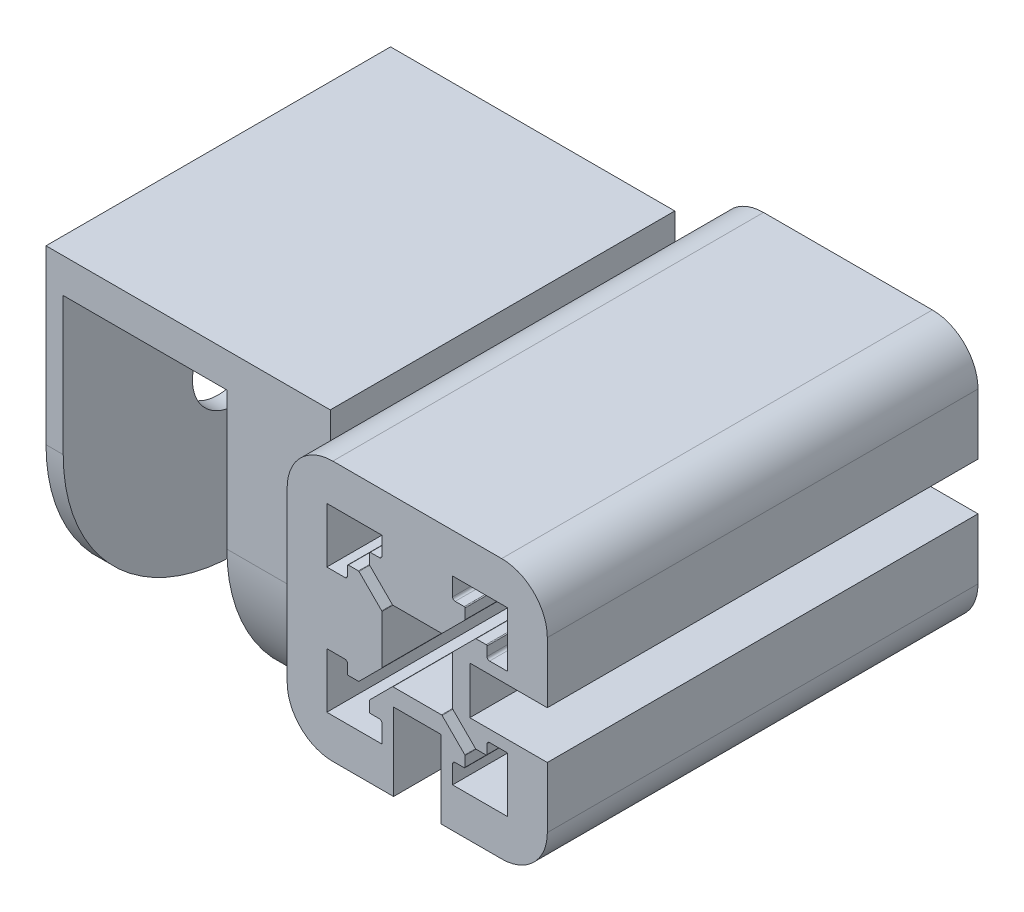
from build123d import *

# Parameters (mm, degrees)
Y_KSEKLIK_EKSTR_ZYON3_DEPTH       = 25
IZIM8_W                           = 20
IZIM8_H                           = 5.3
IZIM8_H_2                         = 14.7
IZIM8_H_3                         = 15.1
IZIM8_H_4                         = 4.9
Y_KSEKLIK_EKSTR_ZYON4_DEPTH       = 33
IZIM9_W                           = 19
IZIM9_H                           = 36
KES_EKSTR_ZYON1_DEPTH             = 36
IZIM11_R                          = 5
KES_EKSTR_ZYON3_DEPTH             = 10
IZIM12_W                          = 19
IZIM12_H                          = 36
KES_EKSTR_ZYON4_DEPTH             = 93
KES_EKSTR_ZYON5_REACH             = 76.836
KES_EKSTR_ZYON5_DIRECTION_2_DEPTH = 2


with BuildPart() as part:
    # izim6 → Y_kseklik-Ekstr_zyon3 (new, symmetric)
    with BuildSketch(Plane.XY):
        with BuildLine():
            Line((-119.371512251, 18.973770729), (-115.371512251, 18.973770729))
            Line((-115.371512251, 18.973770729), (-110.371512251, 18.973770729))
            Line((-110.371512251, 18.973770729), (-110.371512251, 20.773770729))
            Line((-110.371512251, 20.773770729), (-110.371512251, 26.023770729))
            ThreePointArc((-110.371512251, 26.023770729), (-111.92384631, 29.771436669), (-115.671512251, 31.323770729))
            Line((-115.671512251, 31.323770729), (-120.921512251, 31.323770729))
            Line((-120.921512251, 31.323770729), (-122.721512251, 31.323770729))
            Line((-122.721512251, 31.323770729), (-128.221512251, 31.323770729))
            Line((-128.221512251, 31.323770729), (-130.021512251, 31.323770729))
            Line((-130.021512251, 31.323770729), (-135.271512251, 31.323770729))
            ThreePointArc((-135.271512251, 31.323770729), (-139.019178191, 29.771436669), (-140.571512251, 26.023770729))
            Line((-140.571512251, 26.023770729), (-140.571512251, 20.773770729))
            Line((-140.571512251, 20.773770729), (-140.571512251, 16.223770729))
            Line((-140.571512251, 16.223770729), (-140.571512251, 11.673770729))
            Line((-140.571512251, 11.673770729), (-140.571512251, 6.423770729))
            ThreePointArc((-140.571512251, 6.423770729), (-139.019178191, 2.676104789), (-135.271512251, 1.123770729))
            Line((-135.271512251, 1.123770729), (-130.021512251, 1.123770729))
            Line((-130.021512251, 1.123770729), (-128.221512251, 1.123770729))
            Line((-128.221512251, 1.123770729), (-128.221512251, 6.123770729))
            Line((-128.221512251, 6.123770729), (-128.221512251, 10.123770729))
            Line((-128.221512251, 10.123770729), (-122.721512251, 10.123770729))
            Line((-122.721512251, 10.123770729), (-122.721512251, 6.123770729))
            Line((-122.721512251, 6.123770729), (-122.721512251, 1.123770729))
            Line((-122.721512251, 1.123770729), (-120.921512251, 1.123770729))
            Line((-120.921512251, 1.123770729), (-115.671512251, 1.123770729))
            ThreePointArc((-115.671512251, 1.123770729), (-111.92384631, 2.676104789), (-110.371512251, 6.423770729))
            Line((-110.371512251, 6.423770729), (-110.371512251, 11.673770729))
            Line((-110.371512251, 11.673770729), (-110.371512251, 13.473770729))
            Line((-110.371512251, 13.473770729), (-115.371512251, 13.473770729))
            Line((-115.371512251, 13.473770729), (-119.371512251, 13.473770729))
            Line((-119.371512251, 13.473770729), (-119.371512251, 18.973770729))
        make_face()
        with BuildLine():
            Line((-133.871512251, 20.323770729), (-135.071512251, 20.323770729))
            Line((-135.071512251, 20.323770729), (-135.871512251, 20.323770729))
            Line((-135.871512251, 20.323770729), (-135.971512251, 20.323770729))
            Line((-135.971512251, 20.323770729), (-135.971512251, 26.723770729))
            Line((-135.971512251, 26.723770729), (-129.571512251, 26.723770729))
            Line((-129.571512251, 26.723770729), (-129.571512251, 26.623770729))
            Line((-129.571512251, 26.623770729), (-129.571512251, 25.823770729))
            Line((-129.571512251, 25.823770729), (-129.571512251, 24.623770729))
            ThreePointArc((-129.571512251, 24.623770729), (-129.659380216, 24.411638694), (-129.871512251, 24.323770729))
            Line((-129.871512251, 24.323770729), (-130.921512251, 24.323770729))
            ThreePointArc((-130.921512251, 24.323770729), (-130.992222929, 24.294481407), (-131.021512251, 24.223770729))
            Line((-131.021512251, 24.223770729), (-131.021512251, 23.056613441))
            ThreePointArc((-131.021512251, 23.056613441), (-131.013900204, 23.018345098), (-130.992222929, 22.985902763))
            Line((-130.992222929, 22.985902763), (-128.359380216, 20.353060051))
            ThreePointArc((-128.359380216, 20.353060051), (-128.326937882, 20.331382776), (-128.288669538, 20.323770729))
            Line((-128.288669538, 20.323770729), (-122.654354963, 20.323770729))
            ThreePointArc((-122.654354963, 20.323770729), (-122.61608662, 20.331382776), (-122.583644285, 20.353060051))
            Line((-122.583644285, 20.353060051), (-119.950801573, 22.985902763))
            ThreePointArc((-119.950801573, 22.985902763), (-119.929124298, 23.018345098), (-119.921512251, 23.056613441))
            Line((-119.921512251, 23.056613441), (-119.921512251, 24.223770729))
            ThreePointArc((-119.921512251, 24.223770729), (-119.950801573, 24.294481407), (-120.021512251, 24.323770729))
            Line((-120.021512251, 24.323770729), (-121.071512251, 24.323770729))
            ThreePointArc((-121.071512251, 24.323770729), (-121.283644285, 24.411638694), (-121.371512251, 24.623770729))
            Line((-121.371512251, 24.623770729), (-121.371512251, 25.823770729))
            Line((-121.371512251, 25.823770729), (-121.371512251, 26.323770729))
            Line((-121.371512251, 26.323770729), (-121.371512251, 26.723770729))
            Line((-121.371512251, 26.723770729), (-114.971512251, 26.723770729))
            Line((-114.971512251, 26.723770729), (-114.971512251, 20.323770729))
            Line((-114.971512251, 20.323770729), (-115.371512251, 20.323770729))
            Line((-115.371512251, 20.323770729), (-115.871512251, 20.323770729))
            Line((-115.871512251, 20.323770729), (-117.071512251, 20.323770729))
            ThreePointArc((-117.071512251, 20.323770729), (-117.283644285, 20.411638694), (-117.371512251, 20.623770729))
            Line((-117.371512251, 20.623770729), (-117.371512251, 21.673770729))
            ThreePointArc((-117.371512251, 21.673770729), (-117.400801573, 21.744481407), (-117.471512251, 21.773770729))
            Line((-117.471512251, 21.773770729), (-118.638669538, 21.773770729))
            ThreePointArc((-118.638669538, 21.773770729), (-118.676937882, 21.766158682), (-118.709380216, 21.744481407))
            Line((-118.709380216, 21.744481407), (-121.342222929, 19.111638694))
            ThreePointArc((-121.342222929, 19.111638694), (-121.363900204, 19.07919636), (-121.371512251, 19.040928016))
            Line((-121.371512251, 19.040928016), (-121.371512251, 13.406613441))
            ThreePointArc((-121.371512251, 13.406613441), (-121.363900204, 13.368345098), (-121.342222929, 13.335902763))
            Line((-121.342222929, 13.335902763), (-118.709380216, 10.703060051))
            ThreePointArc((-118.709380216, 10.703060051), (-118.676937882, 10.681382776), (-118.638669538, 10.673770729))
            Line((-118.638669538, 10.673770729), (-117.471512251, 10.673770729))
            ThreePointArc((-117.471512251, 10.673770729), (-117.400801573, 10.703060051), (-117.371512251, 10.773770729))
            Line((-117.371512251, 10.773770729), (-117.371512251, 11.823770729))
            ThreePointArc((-117.371512251, 11.823770729), (-117.283644285, 12.035902763), (-117.071512251, 12.123770729))
            Line((-117.071512251, 12.123770729), (-115.871512251, 12.123770729))
            Line((-115.871512251, 12.123770729), (-115.371512251, 12.123770729))
            Line((-115.371512251, 12.123770729), (-114.971512251, 12.123770729))
            Line((-114.971512251, 12.123770729), (-114.971512251, 5.723770729))
            Line((-114.971512251, 5.723770729), (-121.371512251, 5.723770729))
            Line((-121.371512251, 5.723770729), (-121.371512251, 6.123770729))
            Line((-121.371512251, 6.123770729), (-121.371512251, 6.623770729))
            Line((-121.371512251, 6.623770729), (-121.371512251, 7.823770729))
            ThreePointArc((-121.371512251, 7.823770729), (-121.283644285, 8.035902763), (-121.071512251, 8.123770729))
            Line((-121.071512251, 8.123770729), (-120.021512251, 8.123770729))
            ThreePointArc((-120.021512251, 8.123770729), (-119.950801573, 8.153060051), (-119.921512251, 8.223770729))
            Line((-119.921512251, 8.223770729), (-119.921512251, 9.390928016))
            ThreePointArc((-119.921512251, 9.390928016), (-119.929124298, 9.42919636), (-119.950801573, 9.461638694))
            Line((-119.950801573, 9.461638694), (-122.583644285, 12.094481407))
            ThreePointArc((-122.583644285, 12.094481407), (-122.61608662, 12.116158682), (-122.654354963, 12.123770729))
            Line((-122.654354963, 12.123770729), (-128.288669538, 12.123770729))
            ThreePointArc((-128.288669538, 12.123770729), (-128.326937882, 12.116158682), (-128.359380216, 12.094481407))
            Line((-128.359380216, 12.094481407), (-130.992222929, 9.461638694))
            ThreePointArc((-130.992222929, 9.461638694), (-131.013900204, 9.42919636), (-131.021512251, 9.390928016))
            Line((-131.021512251, 9.390928016), (-131.021512251, 8.223770729))
            ThreePointArc((-131.021512251, 8.223770729), (-130.992222929, 8.153060051), (-130.921512251, 8.123770729))
            Line((-130.921512251, 8.123770729), (-129.871512251, 8.123770729))
            ThreePointArc((-129.871512251, 8.123770729), (-129.659380216, 8.035902763), (-129.571512251, 7.823770729))
            Line((-129.571512251, 7.823770729), (-129.571512251, 6.623770729))
            Line((-129.571512251, 6.623770729), (-129.571512251, 6.123770729))
            Line((-129.571512251, 6.123770729), (-129.571512251, 5.723770729))
            Line((-129.571512251, 5.723770729), (-135.971512251, 5.723770729))
            Line((-135.971512251, 5.723770729), (-135.971512251, 12.123770729))
            Line((-135.971512251, 12.123770729), (-135.571512251, 12.123770729))
            Line((-135.571512251, 12.123770729), (-135.071512251, 12.123770729))
            Line((-135.071512251, 12.123770729), (-133.871512251, 12.123770729))
            ThreePointArc((-133.871512251, 12.123770729), (-133.659380216, 12.035902763), (-133.571512251, 11.823770729))
            Line((-133.571512251, 11.823770729), (-133.571512251, 10.773770729))
            ThreePointArc((-133.571512251, 10.773770729), (-133.542222929, 10.703060051), (-133.471512251, 10.673770729))
            Line((-133.471512251, 10.673770729), (-132.304354963, 10.673770729))
            ThreePointArc((-132.304354963, 10.673770729), (-132.26608662, 10.681382776), (-132.233644285, 10.703060051))
            Line((-132.233644285, 10.703060051), (-129.600801573, 13.335902763))
            ThreePointArc((-129.600801573, 13.335902763), (-129.579124298, 13.368345098), (-129.571512251, 13.406613441))
            Line((-129.571512251, 13.406613441), (-129.571512251, 19.040928016))
            ThreePointArc((-129.571512251, 19.040928016), (-129.579124298, 19.07919636), (-129.600801573, 19.111638694))
            Line((-129.600801573, 19.111638694), (-132.233644285, 21.744481407))
            ThreePointArc((-132.233644285, 21.744481407), (-132.26608662, 21.766158682), (-132.304354963, 21.773770729))
            Line((-132.304354963, 21.773770729), (-133.471512251, 21.773770729))
            ThreePointArc((-133.471512251, 21.773770729), (-133.542222929, 21.744481407), (-133.571512251, 21.673770729))
            Line((-133.571512251, 21.673770729), (-133.571512251, 20.623770729))
            ThreePointArc((-133.571512251, 20.623770729), (-133.659380216, 20.411638694), (-133.871512251, 20.323770729))
        make_face(mode=Mode.SUBTRACT)
    extrude(amount=Y_KSEKLIK_EKSTR_ZYON3_DEPTH, both=True)

    # izim8 → Y_kseklik-Ekstr_zyon4 (add)
    with BuildSketch(Plane.ZY.offset(140.571512251)):
        with Locations((-10, 28.673770729)):
            Rectangle(IZIM8_W, IZIM8_H)
        with Locations((10, 28.673770729)):
            Rectangle(IZIM8_W, IZIM8_H)
        with Locations((10, 18.673770729)):
            Rectangle(IZIM8_W, IZIM8_H_2)
        with Locations((-10, 18.673770729)):
            Rectangle(IZIM8_W, IZIM8_H_2)
        with Locations((-10, -1.126229271)):
            Rectangle(IZIM8_W, IZIM8_H_3)
        with Locations((-10, 8.873770729)):
            Rectangle(IZIM8_W, IZIM8_H_4)
        with Locations((10, 8.873770729)):
            Rectangle(IZIM8_W, IZIM8_H_4)
        with Locations((10, -1.126229271)):
            Rectangle(IZIM8_W, IZIM8_H_3)
    extrude(amount=Y_KSEKLIK_EKSTR_ZYON4_DEPTH)

    # izim9 → Kes-Ekstr_zyon1 (cut)
    with BuildSketch(Plane.XZ.offset(8.676229271)):
        with Locations((-162.071512251, 0)):
            Rectangle(IZIM9_W, IZIM9_H)
    extrude(amount=-KES_EKSTR_ZYON1_DEPTH, mode=Mode.SUBTRACT)

    # izim11 → Kes-Ekstr_zyon3 (cut)
    with BuildSketch(Plane.ZY.offset(173.571512251)):
        with Locations(Location((0, 11.323770729, 0), (0, 0, 270))):
            Circle(IZIM11_R)
    extrude(amount=-KES_EKSTR_ZYON3_DEPTH, mode=Mode.SUBTRACT)

    # izim12 → Kes-Ekstr_zyon4 (cut)
    with BuildSketch(Plane(origin=(0, 0, -20), x_dir=(-1, 0, 0), z_dir=(0, 0, -1))):
        with Locations((162.071512251, 9.323770729)):
            Rectangle(IZIM12_W, IZIM12_H)
    extrude(amount=-KES_EKSTR_ZYON4_DEPTH, mode=Mode.SUBTRACT)

    # Kes-Ekstr_zyon5: up to this face of the body (flat: up to its plane)
    kes_ekstr_zyon5_end = Plane(part.part.faces().sort_by_distance((-140.571512251, -1.126229271, 0))[0])
    # izim13 → Kes-Ekstr_zyon5 (cut, up to the picked face)
    with BuildSketch(Plane.ZY.offset(173.571512251), mode=Mode.PRIVATE) as kes_ekstr_zyon5_sk1:
        with BuildLine():
            Line((-20, 11.323770729), (-20, -8.676229271))
            Line((-20, -8.676229271), (3.8e-08, -8.676229271))
            ThreePointArc((3.8e-08, -8.676229271), (-14.14213561, -2.818364908), (-20, 11.323770729))
        make_face()
    kes_ekstr_zyon5_tool1 = split(extrude(kes_ekstr_zyon5_sk1.sketch, amount=-KES_EKSTR_ZYON5_REACH, mode=Mode.PRIVATE), bisect_by=kes_ekstr_zyon5_end, keep=Keep.BOTH, mode=Mode.PRIVATE)
    # izim13 → Kes-Ekstr_zyon5 (cut, up to the picked face)
    with BuildSketch(Plane.ZY.offset(173.571512251), mode=Mode.PRIVATE) as kes_ekstr_zyon5_sk2:
        with BuildLine():
            ThreePointArc((20, 11.323770729), (14.142135637, -2.818364882), (3.8e-08, -8.676229271))
            Line((3.8e-08, -8.676229271), (20, -8.676229271))
            Line((20, -8.676229271), (20, 11.323770729))
        make_face()
    kes_ekstr_zyon5_tool2 = split(extrude(kes_ekstr_zyon5_sk2.sketch, amount=-KES_EKSTR_ZYON5_REACH, mode=Mode.PRIVATE), bisect_by=kes_ekstr_zyon5_end, keep=Keep.BOTH, mode=Mode.PRIVATE)
    add(kes_ekstr_zyon5_tool1.solids().sort_by(Axis((-173.571512, -4.20887, -15.532641), (1, 0, 0)))[0], mode=Mode.SUBTRACT)
    add(kes_ekstr_zyon5_tool2.solids().sort_by(Axis((-173.571512, -4.20887, 15.532641), (1, 0, 0)))[0], mode=Mode.SUBTRACT)

    # izim13 → Kes-Ekstr_zyon5 direction 2 (cut)
    with BuildSketch(Plane.ZY.offset(173.571512251)):
        with BuildLine():
            Line((-20, 11.323770729), (-20, -8.676229271))
            Line((-20, -8.676229271), (3.8e-08, -8.676229271))
            ThreePointArc((3.8e-08, -8.676229271), (-14.14213561, -2.818364908), (-20, 11.323770729))
        make_face()
        with BuildLine():
            ThreePointArc((20, 11.323770729), (14.142135637, -2.818364882), (3.8e-08, -8.676229271))
            Line((3.8e-08, -8.676229271), (20, -8.676229271))
            Line((20, -8.676229271), (20, 11.323770729))
        make_face()
    extrude(amount=KES_EKSTR_ZYON5_DIRECTION_2_DEPTH, mode=Mode.SUBTRACT)


solid = part.part
